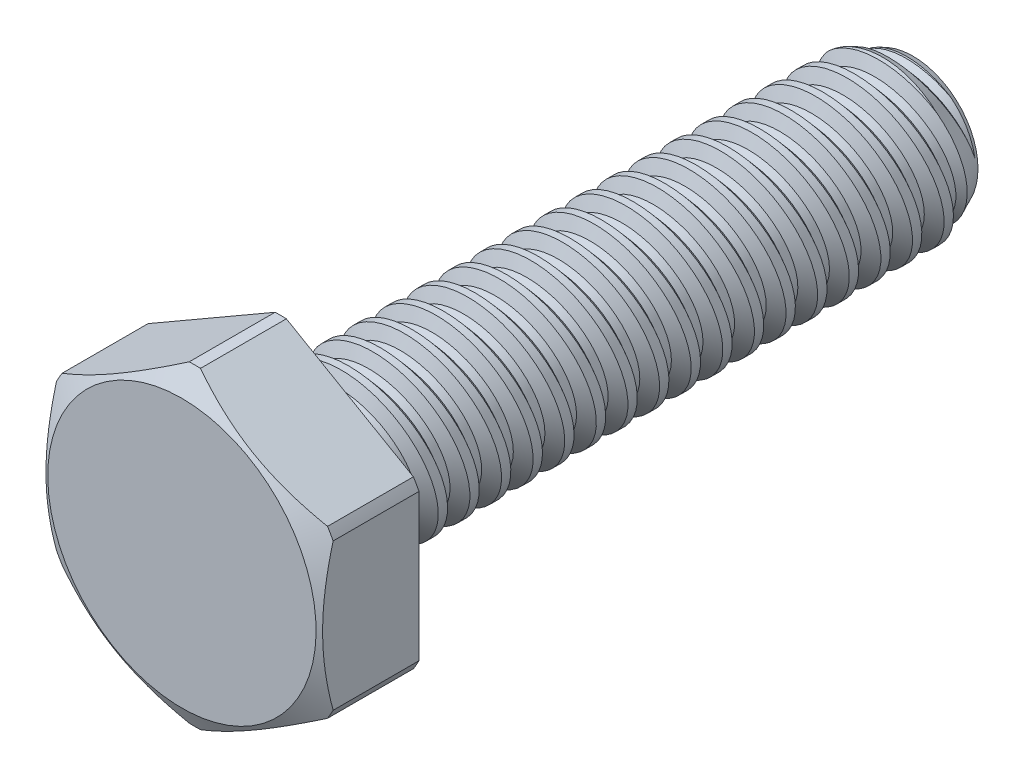
from build123d import *

# Parameters (mm, degrees)
SKETCH1_W            = 25.4
SKETCH1_H            = 3.175
LPATTERN1_COUNT      = 2
LPATTERN1_PITCH      = 1.27
LPATTERN1_COUNT_DIR2 = 20
LPATTERN1_PITCH_DIR2 = 1.27
EXTRUDE1_DEPTH       = 3.96875


with BuildPart() as part:
    # Sketch1 → Revolve1 (revolve)
    with BuildSketch(Plane(origin=(0, 0, 0), x_dir=(0, 0, -1), z_dir=(1, 0, 0)), mode=Mode.PRIVATE) as revolve1_sk:
        with Locations((0, 1.5875)):
            Rectangle(SKETCH1_W, SKETCH1_H)
    revolve(revolve1_sk.sketch.rotate(Axis((0, 0, 12.7), (0, 0, 1)), 125.380956554), axis=Axis((0, 0, 12.7), (0, 0, 1)))

    # Sketch2 → Cut-Revolve1 (revolve, cut)
    with BuildSketch(Plane(origin=(0, 0, 0), x_dir=(0, 0, -1), z_dir=(1, 0, 0)), mode=Mode.PRIVATE) as cut_revolve1_sk:
        Polygon((-11.454662542, 3.424067492), (-12.544332818, 3.206133436), (-12.020353128, 2.609908356), (-11.709018763, 2.672175229), align=None)
    cut_revolve1 = revolve(cut_revolve1_sk.sketch.rotate(Axis((0, -0.272704483, 12.7), (0, 0.19611613513818452, -0.9805806756909201)), 180), axis=Axis((0, -0.272704483, 12.7), (0, 0.19611613513818452, -0.9805806756909201)), mode=Mode.SUBTRACT)

    # Sketch3 → Cut-Revolve2 (revolve, cut)
    with BuildSketch(Plane(origin=(0, 0, 0), x_dir=(0, 0, -1), z_dir=(1, 0, 0)), mode=Mode.PRIVATE) as cut_revolve2_sk:
        Polygon((11.488157058, 3.175), (12.7, 2.609908356), (12.7, 3.175), align=None)
    revolve(cut_revolve2_sk.sketch.rotate(Axis((0, 0, 0), (0, 0, -1)), 234.619043446), axis=Axis((0, 0, 0), (0, 0, -1)), mode=Mode.SUBTRACT)

    # LPattern1: Cut-Revolve1 2 × 20
    with Locations(*[Vector(0, 0, 1) * (i * LPATTERN1_PITCH) + Vector(0, 0, -1) * (j * LPATTERN1_PITCH_DIR2) for i in range(LPATTERN1_COUNT) for j in range(LPATTERN1_COUNT_DIR2) if (i, j) != (0, 0)]):
        add(cut_revolve1, mode=Mode.SUBTRACT)

    # Sketch5 → Extrude1 (add)
    with BuildSketch(Plane.XY.offset(12.7)):
        Polygon((0, 6.415804866), (-5.55625, 3.207902433), (-5.55625, -3.207902433), (0, -6.415804866), (5.55625, -3.207902433), (5.55625, 3.207902433), align=None)
    extrude(amount=EXTRUDE1_DEPTH)

    # Sketch6 → Cut-Revolve3 (revolve, cut)
    with BuildSketch(Plane(origin=(0, 0, 0), x_dir=(0, 0, -1), z_dir=(1, 0, 0)), mode=Mode.PRIVATE) as cut_revolve3_sk:
        Polygon((-16.66875, 5.3895625), (-16.149572178, 6.288804866), (-12.7, 6.288804866), (-12.7, 6.796804866), (-16.66875, 6.796804866), align=None)
    revolve(cut_revolve3_sk.sketch.rotate(Axis((0, 0, 0), (0, 0, 1)), 34.505533911), axis=Axis((0, 0, 0), (0, 0, 1)), mode=Mode.SUBTRACT)


solid = part.part
